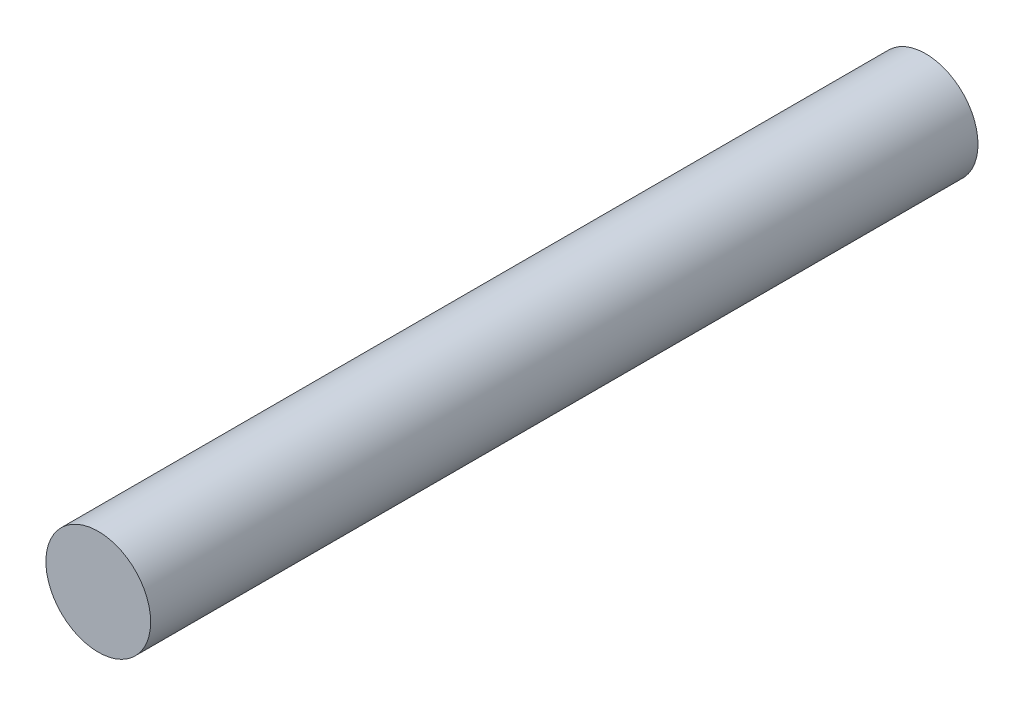
from build123d import *

# Parameters (mm, degrees)
SKETCH1_R           = 2
BOSS_EXTRUDE1_DEPTH = 15.8


with BuildPart() as part:
    # Sketch1 → Boss-Extrude1 (new body, symmetric)
    with BuildSketch(Plane.XY):
        Circle(SKETCH1_R)
    extrude(amount=BOSS_EXTRUDE1_DEPTH, both=True)


solid = part.part
